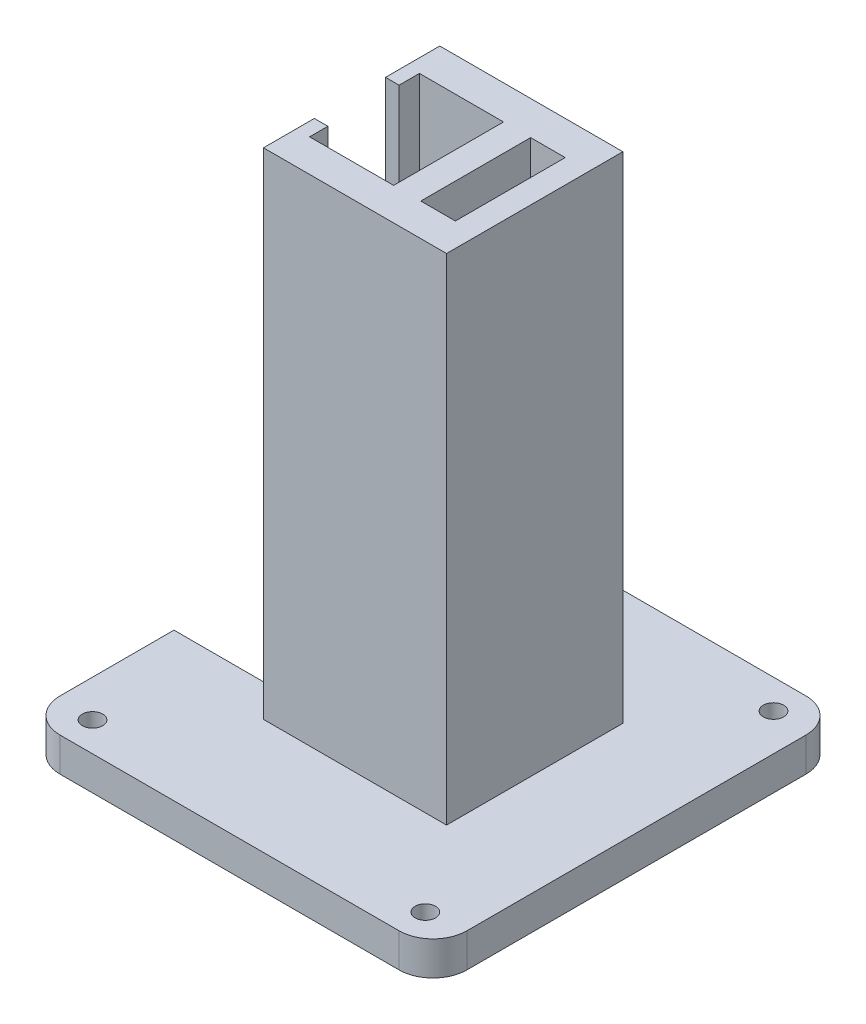
from build123d import *

# Parameters (mm, degrees)
SKETCH1_W           = 30
SKETCH1_H           = 73
BOSS_EXTRUDE1_DEPTH = 26
SKETCH2_W           = 25
SKETCH2_H           = 16.2
CUT_EXTRUDE1_DEPTH  = 74
SKETCH3_W           = 26
SKETCH3_H           = 24
SKETCH3_H_2         = 16.23422306
CUT_EXTRUDE2_DEPTH  = 5
SKETCH5_W           = 60
SKETCH5_H           = 60
BOSS_EXTRUDE2_DEPTH = 5
FILLET1_R           = 5
SKETCH6_R           = 1.5
CUT_EXTRUDE4_DEPTH  = 5
SKETCH7_R           = 1
CUT_EXTRUDE5_DEPTH  = 4
SKETCH8_W           = 15.5
SKETCH8_H           = 5
CUT_EXTRUDE6_DEPTH  = 42
SKETCH9_W           = 5
SKETCH9_H           = 26
CUT_EXTRUDE7_DEPTH  = 73
SKETCH10_W          = 2
SKETCH10_H          = 8
SKETCH10_H_2        = 7.5
BOSS_EXTRUDE3_DEPTH = 78
SKETCH11_W          = 41.5
SKETCH11_H          = 0.7
CUT_EXTRUDE8_DEPTH  = 6
SKETCH13_W          = 0.7
SKETCH13_H          = 5
BOSS_EXTRUDE5_DEPTH = 2
SKETCH15_W          = 4
SKETCH15_H          = 16.2
BOSS_EXTRUDE6_DEPTH = 78


with BuildPart() as part:
    # Sketch1 → Boss-Extrude1 (new body)
    with BuildSketch(Plane.XY):
        Rectangle(SKETCH1_W, SKETCH1_H)
    extrude(amount=BOSS_EXTRUDE1_DEPTH)

    # Sketch2 → Cut-Extrude1 (cut, through all)
    with BuildSketch(Plane(origin=(0, 36.5, 0), x_dir=(1, 0, 0), z_dir=(0, 1, 0))):
        with Locations((-1, -13.1)):
            Rectangle(SKETCH2_W, SKETCH2_H)
    extrude(amount=-CUT_EXTRUDE1_DEPTH, mode=Mode.SUBTRACT)

    # Sketch3 → Cut-Extrude2 (cut)
    with BuildSketch(Plane.ZY.offset(15)):
        with Locations((13, 21.5)):
            Rectangle(SKETCH3_W, SKETCH3_H)
        with Locations((13, -5.5)):
            Rectangle(SKETCH3_W, SKETCH3_H)
        with Locations((13, -28.61711153)):
            Rectangle(SKETCH3_W, SKETCH3_H_2)
    extrude(amount=-CUT_EXTRUDE2_DEPTH, mode=Mode.SUBTRACT)

    # Sketch5 → Boss-Extrude2 (add)
    with BuildSketch(Plane(origin=(0, -36.5, 0), x_dir=(-1, 0, 0), z_dir=(0, -1, 0))):
        with Locations((0, -13)):
            Rectangle(SKETCH5_W, SKETCH5_H)
    extrude(amount=BOSS_EXTRUDE2_DEPTH)

    # Fillet1
    fillet1_edges = [part.edges().sort_by_distance(p)[0] for p in [
        (30, -39, -17),
        (30, -39, 43),
        (-30, -39, 43),
        (-30, -39, -17),
    ]]
    fillet(fillet1_edges, radius=FILLET1_R)

    # Sketch6 → Cut-Extrude4 (cut)
    with BuildSketch(Plane(origin=(0, -36.5, 0), x_dir=(1, 0, 0), z_dir=(0, 1, 0))):
        with Locations((-24.540514854, 12.671548216)):
            Circle(SKETCH6_R)
        with Locations((24.540514854, 12.671548216)):
            Circle(SKETCH6_R)
        with Locations((-24.540514854, -38.671548216)):
            Circle(SKETCH6_R)
        with Locations((24.540514854, -38.671548216)):
            Circle(SKETCH6_R)
    extrude(amount=-CUT_EXTRUDE4_DEPTH, mode=Mode.SUBTRACT)

    # Sketch7 → Cut-Extrude5 (cut)
    with BuildSketch(Plane(origin=(0, 0, 0), x_dir=(-1, 0, 0), z_dir=(0, 0, -1))):
        with Locations((-7, 31.5)):
            Circle(SKETCH7_R)
        with Locations((-12, 24.5)):
            Circle(SKETCH7_R)
        with Locations((-2, 24.5)):
            Circle(SKETCH7_R)
        with Locations((-7, 18.5)):
            Circle(SKETCH7_R)
    extrude(amount=-CUT_EXTRUDE5_DEPTH, mode=Mode.SUBTRACT)

    # Sketch8 → Cut-Extrude6 (cut)
    with BuildSketch(Plane.ZY.offset(30)):
        with Locations((12.75, -39)):
            Rectangle(SKETCH8_W, SKETCH8_H)
    extrude(amount=-CUT_EXTRUDE6_DEPTH, mode=Mode.SUBTRACT)

    # Sketch9 → Cut-Extrude7 (cut)
    with BuildSketch(Plane(origin=(0, 36.5, 0), x_dir=(1, 0, 0), z_dir=(0, 1, 0))):
        with Locations((-12.5, -13)):
            Rectangle(SKETCH9_W, SKETCH9_H)
    extrude(amount=-CUT_EXTRUDE7_DEPTH, mode=Mode.SUBTRACT)

    # Sketch10 → Boss-Extrude3 (add)
    with BuildSketch(Plane(origin=(0, 36.5, 0), x_dir=(1, 0, 0), z_dir=(0, 1, 0))):
        with Locations((-11, -4)):
            Rectangle(SKETCH10_W, SKETCH10_H)
        with Locations((-11, -22.25)):
            Rectangle(SKETCH10_W, SKETCH10_H_2)
    extrude(amount=-BOSS_EXTRUDE3_DEPTH)

    # Sketch11 → Cut-Extrude8 (cut, through all)
    with BuildSketch(Plane(origin=(0, -36.5, 0), x_dir=(1, 0, 0), z_dir=(0, 1, 0))):
        with Locations((-9.25, -20.85)):
            Rectangle(SKETCH11_W, SKETCH11_H)
    extrude(amount=-CUT_EXTRUDE8_DEPTH, mode=Mode.SUBTRACT)

    # Sketch13 → Boss-Extrude5 (add)
    with BuildSketch(Plane.ZY.offset(12)):
        with Locations((20.85, -39)):
            Rectangle(SKETCH13_W, SKETCH13_H)
    extrude(amount=-BOSS_EXTRUDE5_DEPTH)

    # Sketch15 → Boss-Extrude6 (add)
    with BuildSketch(Plane(origin=(0, 36.5, 0), x_dir=(1, 0, 0), z_dir=(0, 1, 0))):
        with Locations((4.4, -13.1)):
            Rectangle(SKETCH15_W, SKETCH15_H)
    extrude(amount=-BOSS_EXTRUDE6_DEPTH)


solid = part.part
